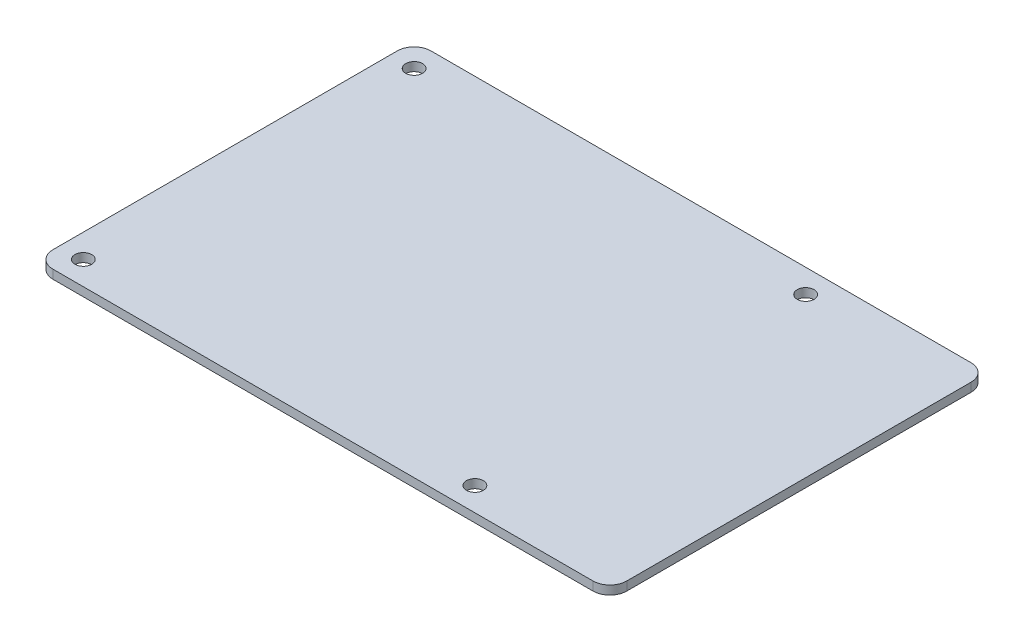
from build123d import *

# Parameters (mm, degrees)
SCHIZZO1_R                   = 1.25
ESTRUSIONE_ESTRUSIONE1_DEPTH = 1.3


with BuildPart() as part:
    # Schizzo1 → Estrusione-Estrusione1 (new body)
    with BuildSketch(Plane(origin=(0, 0, 0), x_dir=(1, 0, 0), z_dir=(0, 1, 0))):
        with BuildLine():
            Line((42.5, -25.5), (42.5, 25.5))
            ThreePointArc((42.5, 25.5), (41.767766953, 27.267766953), (40, 28))
            Line((40, 28), (-40, 28))
            ThreePointArc((-40, 28), (-41.767766953, 27.267766953), (-42.5, 25.5))
            Line((-42.5, 25.5), (-42.5, -25.5))
            ThreePointArc((-42.5, -25.5), (-41.767766953, -27.267766953), (-40, -28))
            Line((-40, -28), (40, -28))
            ThreePointArc((40, -28), (41.767766953, -27.267766953), (42.5, -25.5))
        make_face()
        with Locations(Location((19, 24.5, 0), (0, 0, 90))):  # turned: the seam where the file's is
            Circle(SCHIZZO1_R, mode=Mode.SUBTRACT)
        with Locations(Location((-39, 24.5, 0), (0, 0, 90))):  # turned: the seam where the file's is
            Circle(SCHIZZO1_R, mode=Mode.SUBTRACT)
        with Locations(Location((-39, -24.5, 0), (0, 0, 90))):  # turned: the seam where the file's is
            Circle(SCHIZZO1_R, mode=Mode.SUBTRACT)
        with Locations(Location((19, -24.5, 0), (0, 0, 90))):  # turned: the seam where the file's is
            Circle(SCHIZZO1_R, mode=Mode.SUBTRACT)
    extrude(amount=-ESTRUSIONE_ESTRUSIONE1_DEPTH)


solid = part.part
